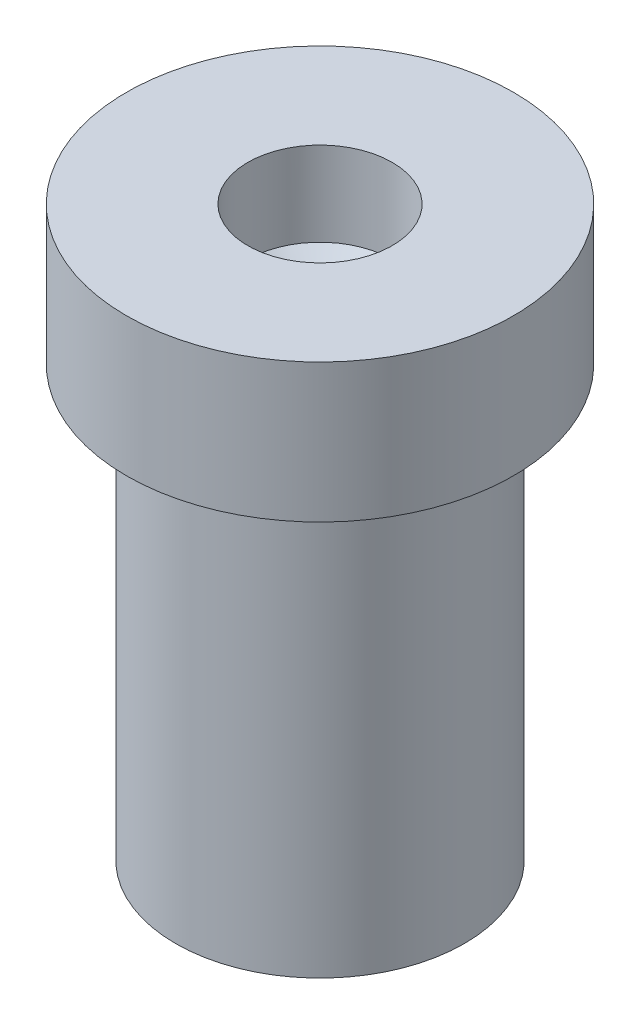
from build123d import *


with BuildPart() as part:
    # Sketch1 → Revolve1 (revolve)
    with BuildSketch(Plane.XY):
        Polygon((0, -10.425), (4.1, -10.425), (4.1, 1.775), (5.495413457, 1.775), (5.495413457, 5.710216911), (2.05, 5.710216911), (2.05, 3.320896934), (0, 1.775), align=None)
    revolve(axis=Axis((0, -10.425, 0), (0, 1, 0)))


solid = part.part
